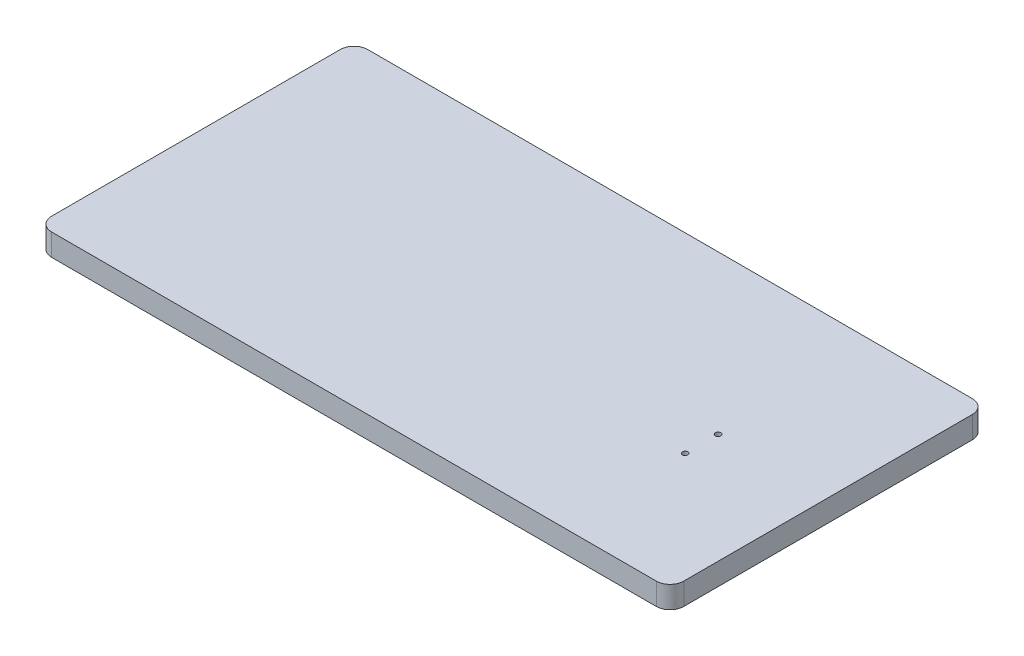
from build123d import *

# Parameters (mm, degrees)
EXTRUDE_1_DEPTH     = 8
CUT_EXTRUDE_9_REACH = 581.256
SKETCH_15_R         = 2


with BuildPart() as part:
    # 草圖1 → 填料-伸長1 (new, symmetric)
    with BuildSketch(Plane(origin=(0, 0, 0), x_dir=(1, 0, 0), z_dir=(0, 1, 0))):
        with BuildLine():
            ThreePointArc((567.5, 105), (564.571067812, 112.071067812), (557.5, 115))
            Line((557.5, 115), (117.5, 115))
            ThreePointArc((117.5, 115), (110.428932188, 112.071067812), (107.5, 105))
            Line((107.5, 105), (107.5, -105))
            ThreePointArc((107.5, -105), (110.428932188, -112.071067812), (117.5, -115))
            Line((117.5, -115), (557.5, -115))
            ThreePointArc((557.5, -115), (564.571067812, -112.071067812), (567.5, -105))
            Line((567.5, -105), (567.5, 105))
        make_face()
    extrude(amount=EXTRUDE_1_DEPTH, both=True)

    # 草圖15 → 除料-伸長9 (cut, up to next)
    with BuildSketch(Plane(origin=(0, 8, 0), x_dir=(1, 0, 0), z_dir=(0, 1, 0)), mode=Mode.PRIVATE) as cut_extrude_9_sk1:
        with Locations((487.5, -24)):
            Circle(SKETCH_15_R)
    cut_extrude_9_tool1 = extrude(cut_extrude_9_sk1.sketch, amount=-CUT_EXTRUDE_9_REACH, mode=Mode.PRIVATE) & part.part
    # 草圖15 → 除料-伸長9 (cut, up to next)
    with BuildSketch(Plane(origin=(0, 8, 0), x_dir=(1, 0, 0), z_dir=(0, 1, 0)), mode=Mode.PRIVATE) as cut_extrude_9_sk2:
        with Locations((487.5, 0)):
            Circle(SKETCH_15_R)
    cut_extrude_9_tool2 = extrude(cut_extrude_9_sk2.sketch, amount=-CUT_EXTRUDE_9_REACH, mode=Mode.PRIVATE) & part.part
    add(cut_extrude_9_tool1.solids().sort_by_distance((487.5, 8, 24))[0], mode=Mode.SUBTRACT)
    add(cut_extrude_9_tool2.solids().sort_by_distance((487.5, 8, 0))[0], mode=Mode.SUBTRACT)


solid = part.part
